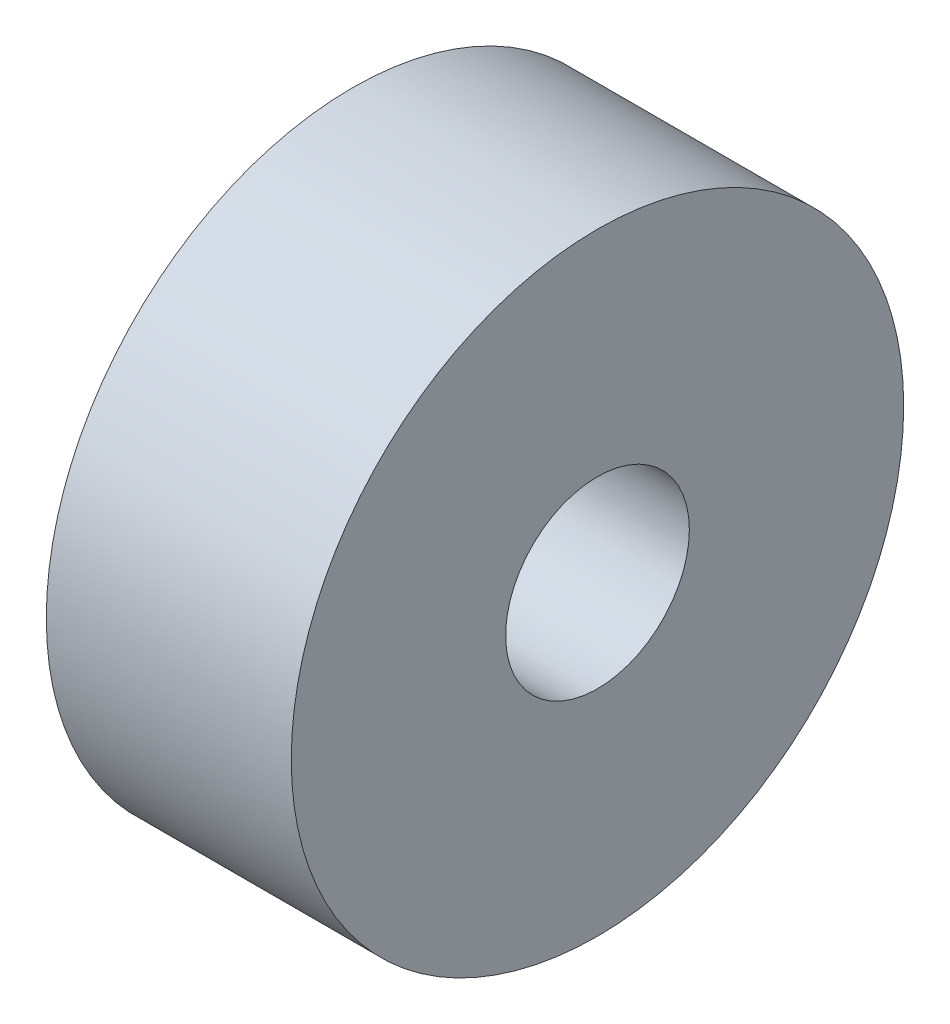
from build123d import *

# Parameters (mm, degrees)
SKETCH1_R           = 5
SKETCH1_R_2         = 1.5
BOSS_EXTRUDE1_DEPTH = 4


with BuildPart() as part:
    # Sketch1 → Boss-Extrude1 (new body)
    with BuildSketch(Plane(origin=(0, 0, 0), x_dir=(0, 0, -1), z_dir=(1, 0, 0))):
        Circle(SKETCH1_R)
        Circle(SKETCH1_R_2, mode=Mode.SUBTRACT)
    extrude(amount=BOSS_EXTRUDE1_DEPTH)


solid = part.part
